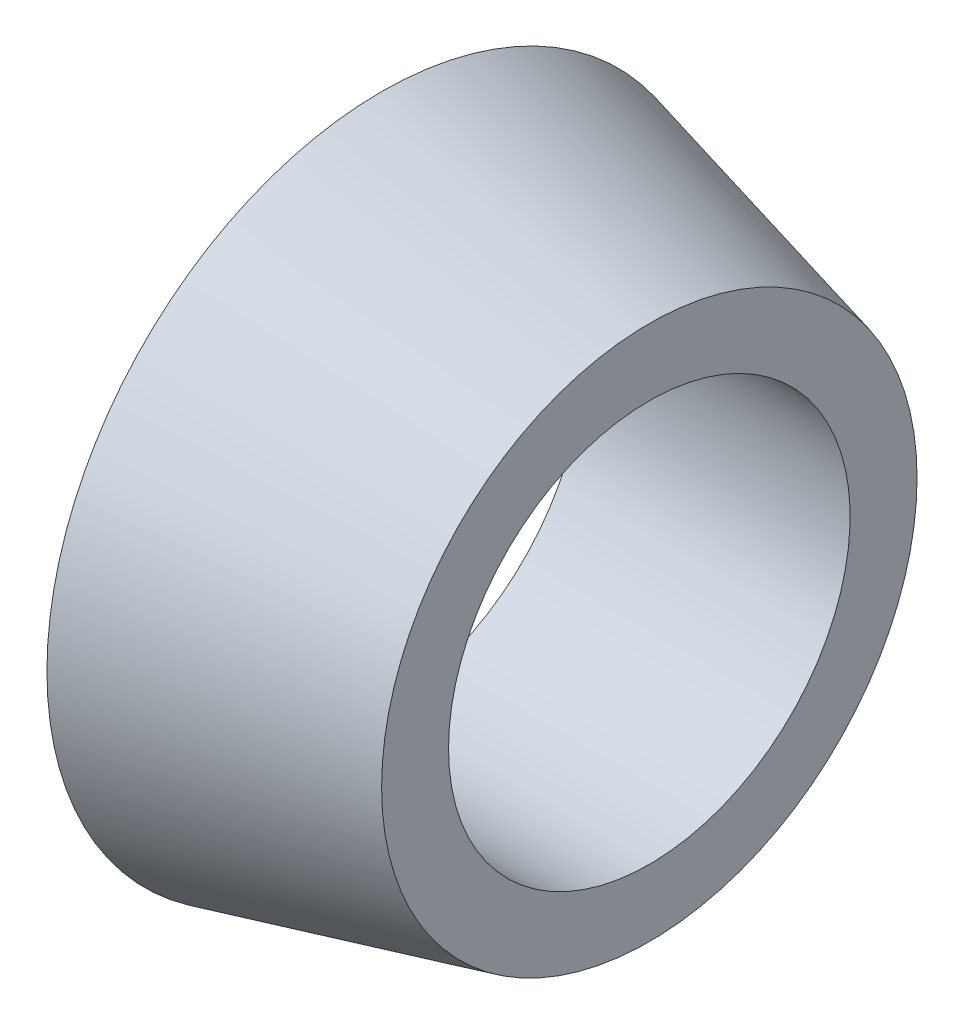
from build123d import *


with BuildPart() as part:
    # Szkic1 → Obrót1 (revolve)
    with BuildSketch(Plane.XY):
        Polygon((0, 6), (0, 10), (8, 8), (8, 6), align=None)
    revolve(axis=Axis((0, 0, 0), (1, 0, 0)))


solid = part.part
